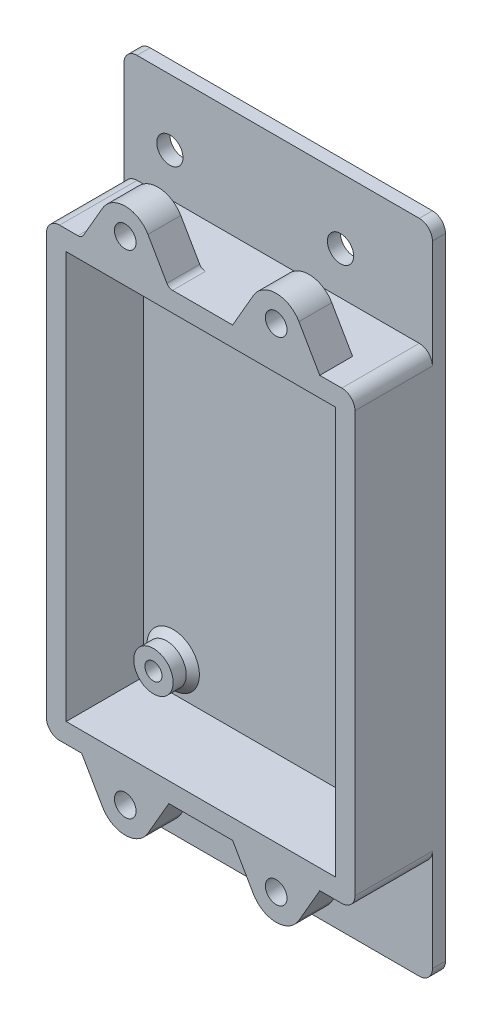
from build123d import *

# Parameters (mm, degrees)
SKETCH_1_W               = 40
SKETCH_1_H               = 100
SKETCH_1_R               = 2
EXTRUDE_1_DEPTH          = 2
SKETCH_2_W               = 47
SKETCH_2_H               = 68
SKETCH_2_W_2             = 41
SKETCH_2_H_2             = 62
EXTRUDE_2_DEPTH          = 11.8
SKETCH_3_W               = 7
SKETCH_3_H               = 100
EXTRUDE_3_DEPTH          = 2
SKETCH_4_R               = 3
SKETCH_4_R_2             = 1.3
EXTRUDE_4_DEPTH          = 3
SKETCH_5_R               = 1.3
CUT_EXTRUDE_1_DEPTH      = 3.5
SKETCH_6_R               = 1.65
EXTRUDE_5_DEPTH          = 5
CUT_EXTRUDE_2_DEPTH      = 2
FILLET_1_R               = 1
MIRROR_5_COPY_1_SKETCH_R = 1.65
MIRROR_5_COPY_1_DEPTH    = 5
MIRROR_5_COPY_2_DEPTH    = 2
FILLET_2_R               = 2
CHAMFER_1_SIZE           = 1


with BuildPart() as part:
    # 草图1 → 凸台-拉伸1 (new body)
    with BuildSketch(Plane.XY):
        Rectangle(SKETCH_1_W, SKETCH_1_H)
        with Locations((-13, 40)):
            Circle(SKETCH_1_R, mode=Mode.SUBTRACT)
        with Locations((13, 40)):
            Circle(SKETCH_1_R, mode=Mode.SUBTRACT)
        with Locations((-13, -40)):
            Circle(SKETCH_1_R, mode=Mode.SUBTRACT)
        with Locations((13, -40)):
            Circle(SKETCH_1_R, mode=Mode.SUBTRACT)
    extrude(amount=EXTRUDE_1_DEPTH)

    # 草图2 → 凸台-拉伸2 (add)
    with BuildSketch(Plane.XY.offset(2)):
        with Locations((3.5, -0.496887342)):
            Rectangle(SKETCH_2_W, SKETCH_2_H)
        with Locations((3.5, -0.496887342)):
            Rectangle(SKETCH_2_W_2, SKETCH_2_H_2, mode=Mode.SUBTRACT)
    extrude(amount=EXTRUDE_2_DEPTH)

    # 草图3 → 凸台-拉伸3 (add)
    with BuildSketch(Plane(origin=(0, 0, 0), x_dir=(-1, 0, 0), z_dir=(0, 0, -1))):
        with Locations((-23.5, 0)):
            Rectangle(SKETCH_3_W, SKETCH_3_H)
    extrude(amount=-EXTRUDE_3_DEPTH)

    # 草图4 → 凸台-拉伸4 (add)
    with BuildSketch(Plane.XY.offset(2)):
        with Locations(Location((-12.5, 26.003112658, 0), (0, 0, 180))):
            Circle(SKETCH_4_R)
        with Locations((-12.5, 26.003112658)):
            Circle(SKETCH_4_R_2, mode=Mode.SUBTRACT)
        with Locations(Location((19.5, 26.003112658, 0), (0, 0, 180))):
            Circle(SKETCH_4_R)
        with Locations((19.5, 26.003112658)):
            Circle(SKETCH_4_R_2, mode=Mode.SUBTRACT)
        with Locations(Location((19.5, -26.996887342, 0), (0, 0, 180))):
            Circle(SKETCH_4_R)
        with Locations((19.5, -26.996887342)):
            Circle(SKETCH_4_R_2, mode=Mode.SUBTRACT)
        with Locations(Location((-12.5, -26.996887342, 0), (0, 0, 180))):
            Circle(SKETCH_4_R)
        with Locations((-12.5, -26.996887342)):
            Circle(SKETCH_4_R_2, mode=Mode.SUBTRACT)
    extrude(amount=EXTRUDE_4_DEPTH)

    # 草图5 → 切除-拉伸1 (cut)
    with BuildSketch(Plane.XY.offset(5)):
        with Locations((-12.5, -26.996887342)):
            Circle(SKETCH_5_R)
        with Locations((19.5, -26.996887342)):
            Circle(SKETCH_5_R)
        with Locations((19.5, 26.003112658)):
            Circle(SKETCH_5_R)
        with Locations((-12.5, 26.003112658)):
            Circle(SKETCH_5_R)
    extrude(amount=-CUT_EXTRUDE_1_DEPTH, mode=Mode.SUBTRACT)

    # 草图6 → 凸台-拉伸5 (add)
    with BuildSketch(Plane.XY.offset(13.8)):
        with BuildLine():
            Line((-14.639528096, 33.503112658), (-1.360471904, 33.503112658))
            Line((-1.360471904, 33.503112658), (-4.535898385, 39.003112658))
            ThreePointArc((-4.535898385, 39.003112658), (-8, 41.003112658), (-11.464101615, 39.003112658))
            Line((-11.464101615, 39.003112658), (-14.639528096, 33.503112658))
        make_face()
        with Locations((-8, 37.003112658)):
            Circle(SKETCH_6_R, mode=Mode.SUBTRACT)
    extrude_5 = extrude(amount=-EXTRUDE_5_DEPTH)

    # 草图7 → 切除-拉伸2 (cut)
    with BuildSketch(Plane(origin=(0, 0, 8.8), x_dir=(-1, 0, 0), z_dir=(0, 0, -1))):
        Polygon((6.325684219, 39.903112658), (4.651368439, 37.003112658), (6.325684219, 34.103112658), (9.674315781, 34.103112658), (11.348631561, 37.003112658), (9.674315781, 39.903112658), align=None)
    cut_extrude_2 = extrude(amount=-CUT_EXTRUDE_2_DEPTH, mode=Mode.SUBTRACT)

    # 圆角1
    fillet_1_edges = [part.edges().sort_by_distance(p)[0] for p in [
        (-14.639528096, 33.503112658, 11.3),
        (-1.360471904, 33.503112658, 11.3),
    ]]
    fillet(fillet_1_edges, radius=FILLET_1_R)

    # 镜向1: 凸台-拉伸5, 切除-拉伸2 across plane
    add(extrude_5.mirror(Plane(origin=(3.5, 0, 0), x_dir=(0, 0, 1), z_dir=(1, 0, 0))))
    add(cut_extrude_2.mirror(Plane(origin=(3.5, 0, 0), x_dir=(0, 0, 1), z_dir=(1, 0, 0))), mode=Mode.SUBTRACT)

    # 镜向5: 凸台-拉伸5, 切除-拉伸2 across plane
    add(extrude_5.mirror(Plane(origin=(0, -0.496887342, 0), x_dir=(0, 0, 1), z_dir=(0, -1, 0))))
    add(cut_extrude_2.mirror(Plane(origin=(0, -0.496887342, 0), x_dir=(0, 0, 1), z_dir=(0, -1, 0))), mode=Mode.SUBTRACT)

    # 镜向5 copy 1 sketch → 镜向5 copy 1 (add)
    with BuildSketch(Plane(origin=(7, -0.993774684, 13.8), x_dir=(-1, 0, 0), z_dir=(0, 0, 1))):
        with BuildLine():
            Line((-14.639528096, 33.503112658), (-1.360471904, 33.503112658))
            Line((-1.360471904, 33.503112658), (-4.535898385, 39.003112658))
            ThreePointArc((-4.535898385, 39.003112658), (-8, 41.003112658), (-11.464101615, 39.003112658))
            Line((-11.464101615, 39.003112658), (-14.639528096, 33.503112658))
        make_face()
        with Locations((-8, 37.003112658)):
            Circle(MIRROR_5_COPY_1_SKETCH_R, mode=Mode.SUBTRACT)
    extrude(amount=-MIRROR_5_COPY_1_DEPTH)

    # 镜向5 copy 2 sketch → 镜向5 copy 2 (cut)
    with BuildSketch(Plane(origin=(7, -0.993774684, 8.8), x_dir=(1, 0, 0), z_dir=(0, 0, -1))):
        Polygon((6.325684219, 39.903112658), (4.651368439, 37.003112658), (6.325684219, 34.103112658), (9.674315781, 34.103112658), (11.348631561, 37.003112658), (9.674315781, 39.903112658), align=None)
    extrude(amount=-MIRROR_5_COPY_2_DEPTH, mode=Mode.SUBTRACT)

    # 圆角2
    fillet_2_edges = [part.edges().sort_by_distance(p)[0] for p in [
        (27, 33.503112658, 7.9),
        (-20, 33.503112658, 7.9),
        (-20, -34.496887342, 7.9),
        (27, -34.496887342, 7.9),
        (27, -50, 1),
        (27, 50, 1),
        (-20, -50, 1),
        (-20, 50, 1),
    ]]
    fillet(fillet_2_edges, radius=FILLET_2_R)

    # 倒角1
    chamfer_1_edges = [part.edges().sort_by_distance(p)[0] for p in [
        (-9.5, 26.003112658, 2),
        (22.5, 26.003112658, 2),
        (22.5, -26.996887342, 2),
        (-9.5, -26.996887342, 2),
    ]]
    chamfer(chamfer_1_edges, length=CHAMFER_1_SIZE)


solid = part.part
